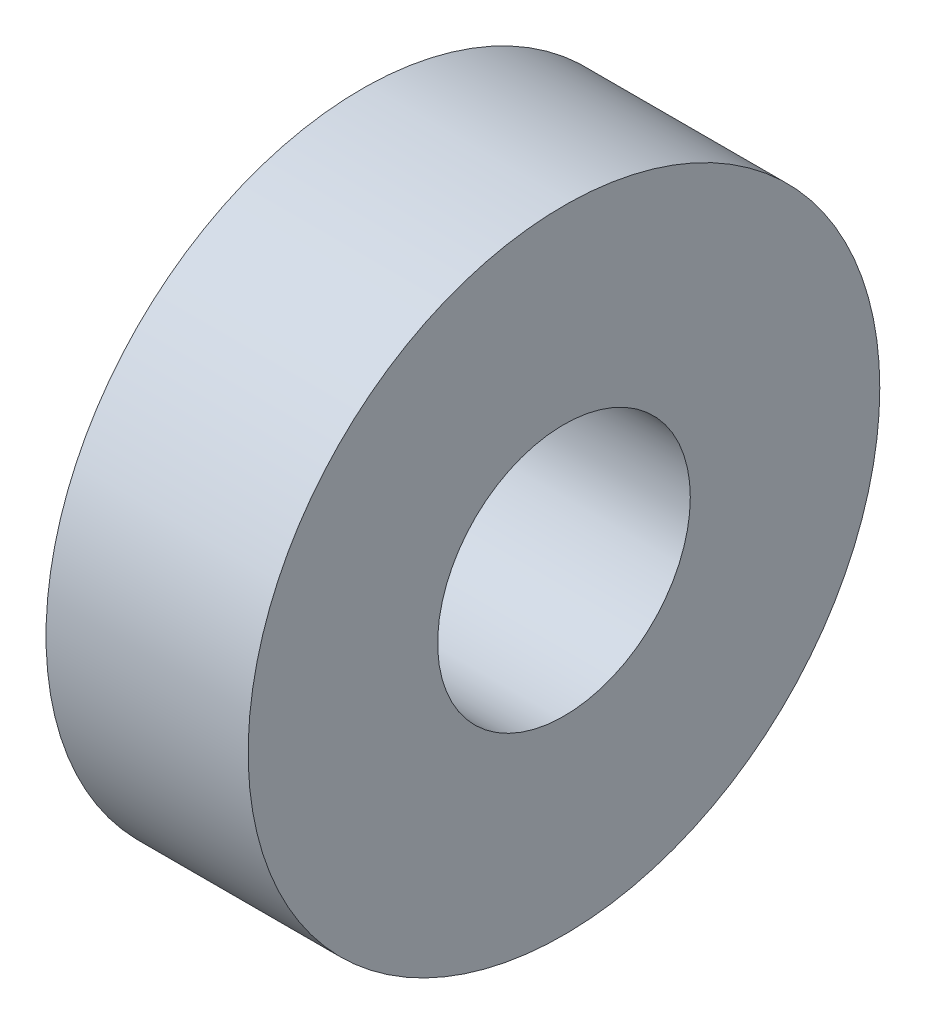
from build123d import *

# Parameters (mm, degrees)
SKETCH1_R           = 7.9375
SKETCH1_R_2         = 3.175
BOSS_EXTRUDE1_DEPTH = 5.08


with BuildPart() as part:
    # Sketch1 → Boss-Extrude1 (new body)
    with BuildSketch(Plane(origin=(0, 0, 0), x_dir=(0, 0, -1), z_dir=(1, 0, 0))):
        Circle(SKETCH1_R)
        Circle(SKETCH1_R_2, mode=Mode.SUBTRACT)
    extrude(amount=BOSS_EXTRUDE1_DEPTH)


solid = part.part
